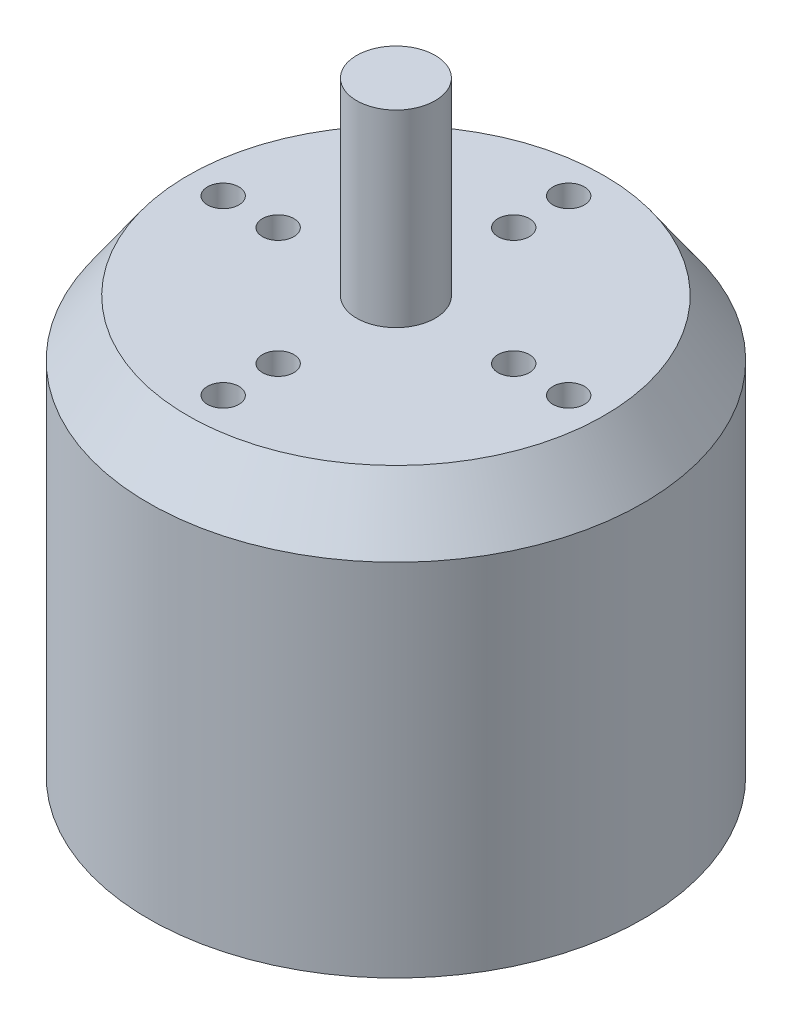
from build123d import *

# Parameters (mm, degrees)
SKETCH1_W                 = 31.5
SKETCH1_H                 = 55
SKETCH1_W_2               = 5
SKETCH1_H_2               = 24
CHAMFER1_SIZE             = 5
CHAMFER1_SIZE2            = 7.140740034
CHAMFER2_SIZE             = 2
CHAMFER2_SIZE2            = 2.856296013
F_4_0MM_DOWEL_HOLE1_D     = 4
F_4_0MM_DOWEL_HOLE1_DEPTH = 20
F_4_0MM_DOWEL_HOLE1_TIP   = 1.201721238


with BuildPart() as part:
    # Sketch1 → Revolve1 (revolve)
    with BuildSketch(Plane.XY):
        with Locations((15.75, 27.5)):
            Rectangle(SKETCH1_W, SKETCH1_H)
        with Locations((2.5, 67)):
            Rectangle(SKETCH1_W_2, SKETCH1_H_2)
    revolve(axis=Axis((0, 55, 0), (0, 1, 0)))

    # Chamfer1
    chamfer1_edges = [part.edges().sort_by_distance(p)[0] for p in [
        (-31.5, 55, 0),
    ]]
    chamfer1_side = [part.faces().sort_by_distance(p)[0] for p in [
        (-30.609045456, 55, 0),
    ]]
    chamfer(chamfer1_edges, length=CHAMFER1_SIZE, length2=CHAMFER1_SIZE2, reference=chamfer1_side[0])

    # Chamfer2
    chamfer2_edges = [part.edges().sort_by_distance(p)[0] for p in [
        (-31.5, 0, 0),
    ]]
    chamfer2_side = [part.faces().sort_by_distance(p)[0] for p in [
        (-31.5, 23.929629983, 0),
    ]]
    chamfer(chamfer2_edges, length=CHAMFER2_SIZE, length2=CHAMFER2_SIZE2, reference=chamfer2_side[0])

    # Ø4.0mm Dowel Hole1
    with Locations(Plane(origin=(0, 55, 0), x_dir=(1, 0, 0), z_dir=(0, 1, 0))):
        with Locations((15, 0), (0, 22), (22, 0), (0, -22), (-22, 0), (0, 15), (-15, 0), (0, -15)):
            Hole(F_4_0MM_DOWEL_HOLE1_D / 2, depth=F_4_0MM_DOWEL_HOLE1_DEPTH)
            with Locations((0, 0, -(F_4_0MM_DOWEL_HOLE1_DEPTH + F_4_0MM_DOWEL_HOLE1_TIP / 2))):  # 118° drill point
                Cone(0, F_4_0MM_DOWEL_HOLE1_D / 2, F_4_0MM_DOWEL_HOLE1_TIP, mode=Mode.SUBTRACT)


solid = part.part
